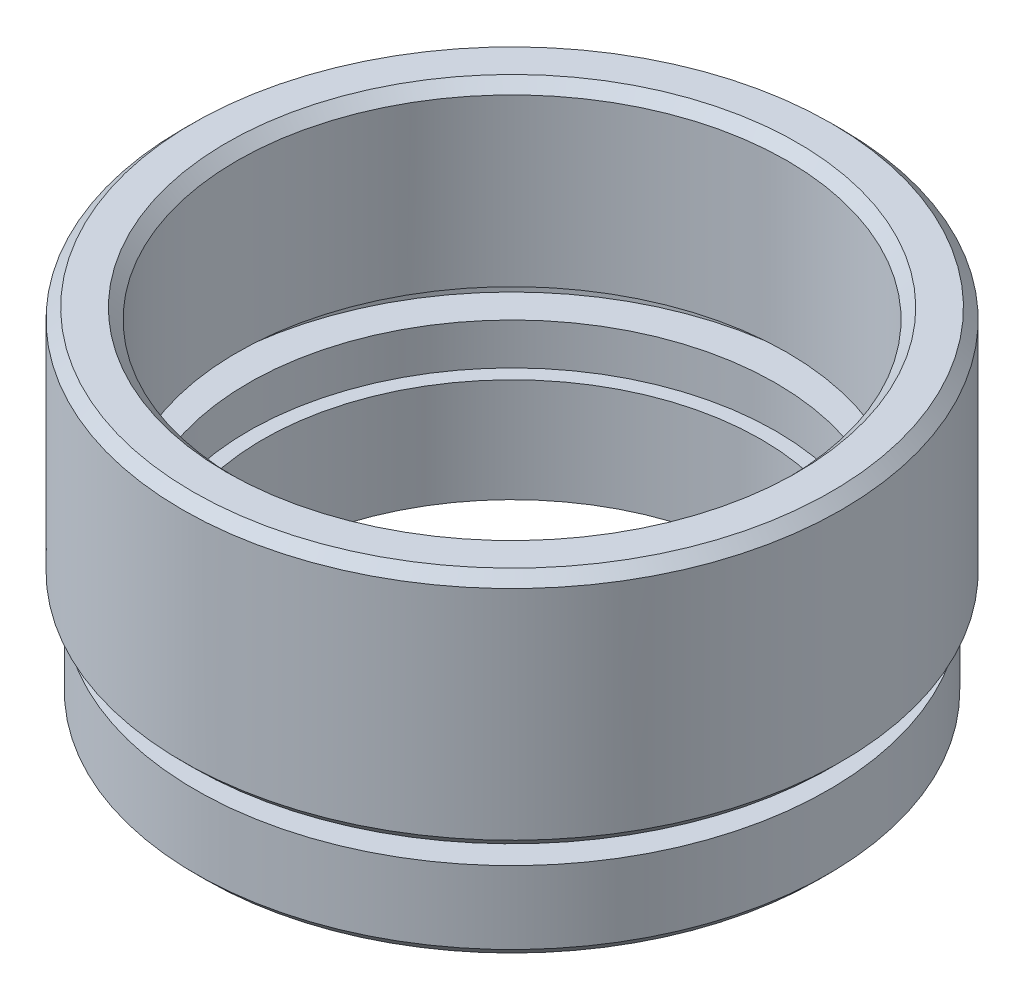
from build123d import *

# Parameters (mm, degrees)
CHAMFER_1_SIZE = 0.5


with BuildPart() as part:
    # 草图1 → 旋转1 (revolve)
    with BuildSketch(Plane.XY, mode=Mode.PRIVATE) as revolve_1_sk:
        Polygon((12, 0), (15.25, 0), (15.25, 4), (13.75, 4), (13.75, 5), (15.875, 5), (15.875, 16.5), (13.25, 16.5), (13.25, 8), (14.35, 8), (14.35, 7), (12.7, 7), (12.7, 5), (12, 5), align=None)
    revolve(revolve_1_sk.sketch.rotate(Axis((0, 0, 0), (0, 1, 0)), 90), axis=Axis((0, 0, 0), (0, 1, 0)))  # turned: the seam where the file's is

    # 倒角1
    chamfer_1_edges = [part.edges().sort_by_distance(p)[0] for p in [
        (0, 16.5, 13.25),
        (0, 16.5, 15.875),
        (0, 5, 15.875),
        (0, 0, 15.25),
    ]]
    chamfer(chamfer_1_edges, length=CHAMFER_1_SIZE)


solid = part.part
